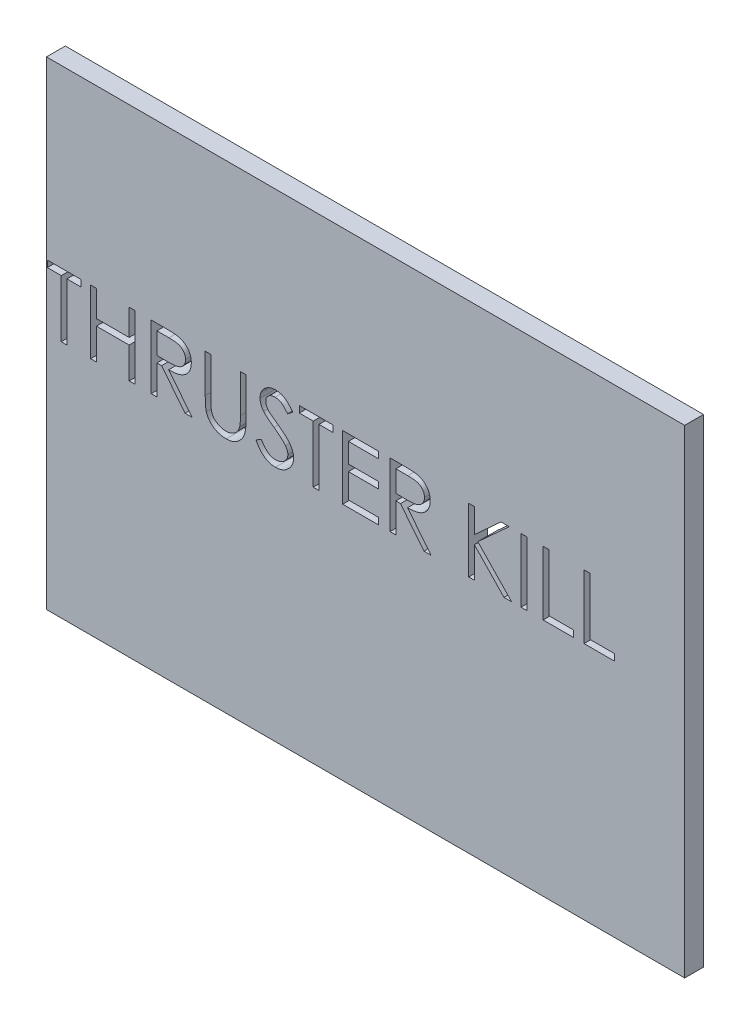
from build123d import *

# Parameters (mm, degrees)
SKETCH1_W               = 101.6
SKETCH1_H               = 76.2
BOSS_EXTRUDE1_DEPTH     = 3
SKETCH2_W               = 0.911794872
SKETCH2_H               = 10.16
CUT_EXTRUDE1_DEPTH      = 1
CUT_EXTRUDE1_DEPTH_BACK = 4


with BuildPart() as part:
    # Sketch1 → Boss-Extrude1 (new body)
    with BuildSketch(Plane.XY):
        Rectangle(SKETCH1_W, SKETCH1_H)
    extrude(amount=BOSS_EXTRUDE1_DEPTH)

    # Sketch2 → Cut-Extrude1 (cut, two sides)
    with BuildSketch(Plane.XY.offset(3)) as cut_extrude1_sk:
        Polygon((-50.66974359, 9.117948718), (-50.66974359, 10.16), (-45.329230769, 10.16), (-45.329230769, 9.117948718), (-47.543589744, 9.117948718), (-47.543589744, 0), (-48.455384615, 0), (-48.455384615, 9.117948718), align=None)
        Polygon((-43.766153846, 10.16), (-42.854358974, 10.16), (-42.854358974, 5.991794872), (-37.644102564, 5.991794872), (-37.644102564, 10.16), (-36.732307692, 10.16), (-36.732307692, 0), (-37.644102564, 0), (-37.644102564, 4.94974359), (-42.854358974, 4.94974359), (-42.854358974, 0), (-43.766153846, 0), align=None)
        with BuildLine():
            Line((-34.127179487, 10.16), (-32.093958333, 10.16))
            add(Edge.make_bspline(
                [(-32.093958333, 10.16), (-31.958275515, 10.159548356), (-31.697749473, 10.15868115), (-31.324519636, 10.153845678), (-30.985387263, 10.139986405), (-30.680529673, 10.128059775), (-30.409952457, 10.106311739), (-30.172825922, 10.085525404), (-29.970242205, 10.058315005), (-29.847608534, 10.033044406), (-29.792083333, 10.021602564)],
                knots=[0, 0, 0, 0, 0.000407056, 0.000781593, 0.001119667, 0.001425287, 0.00169674, 0.001933889, 0.0021394, 0.002309438, 0.002309438, 0.002309438, 0.002309438], degree=3))
            add(Edge.make_bspline(
                [(-29.792083333, 10.021602564), (-29.717750962, 10.003236868), (-29.570671929, 9.966897266), (-29.358908309, 9.890088825), (-29.157118157, 9.801204429), (-28.966139696, 9.696806886), (-28.786929513, 9.57612124), (-28.617639788, 9.441230919), (-28.457502329, 9.292874002), (-28.312993368, 9.127310005), (-28.176736007, 8.953613165), (-28.061815879, 8.765787403), (-27.962751584, 8.569375654), (-27.883879455, 8.362380407), (-27.820370823, 8.146809092), (-27.775590654, 7.920709042), (-27.748735778, 7.685110326), (-27.746001706, 7.524414225), (-27.744615385, 7.442932692)],
                knots=[0, 0, 0, 0, 0.00022956, 0.000454224, 0.000674718, 0.00089059, 0.001106221, 0.001322045, 0.001539474, 0.001760044, 0.001980679, 0.002200948, 0.002419395, 0.002639748, 0.002864522, 0.003092834, 0.003330402, 0.003574768, 0.003574768, 0.003574768, 0.003574768], degree=3))
            add(Edge.make_bspline(
                [(-27.744615385, 7.442932692), (-27.748879676, 7.307557646), (-27.757200414, 7.043405867), (-27.834779572, 6.660051994), (-27.961856555, 6.302451012), (-28.136966445, 5.971053183), (-28.359962409, 5.672318281), (-28.627968088, 5.409927702), (-28.941132995, 5.190355842), (-29.232664952, 5.038092843), (-29.4901896, 4.940577428), (-29.702194874, 4.871964455), (-29.933456729, 4.818952579), (-30.181759391, 4.771461454), (-30.448136174, 4.735606249), (-30.731948631, 4.709345278), (-31.033399174, 4.692932382), (-31.240486301, 4.690488162), (-31.347019231, 4.689230769)],
                knots=[0, 0, 0, 0, 0.000405752, 0.000791727, 0.001167671, 0.001540962, 0.001911786, 0.002281672, 0.002661169, 0.003055321, 0.003264715, 0.003486782, 0.00372324, 0.003975915, 0.004245039, 0.004529174, 0.004830832, 0.005150425, 0.005150425, 0.005150425, 0.005150425], degree=3))
            Line((-31.347019231, 4.689230769), (-27.614358974, 0))
            Line((-27.614358974, 0), (-28.741891026, 0))
            Line((-28.741891026, 0), (-32.474551282, 4.689230769))
            Line((-32.474551282, 4.689230769), (-33.215384615, 4.689230769))
            Line((-33.215384615, 4.689230769), (-33.215384615, 0))
            Line((-33.215384615, 0), (-34.127179487, 0))
            Line((-34.127179487, 0), (-34.127179487, 10.16))
        make_face()
        with BuildLine():
            Line((-33.215384615, 9.117948718), (-33.215384615, 5.731282051))
            Line((-33.215384615, 5.731282051), (-31.355160256, 5.717035256))
            add(Edge.make_bspline(
                [(-31.355160256, 5.717035256), (-31.268306658, 5.716996832), (-31.099959646, 5.716922355), (-30.856408002, 5.728515717), (-30.629636478, 5.741704321), (-30.420512466, 5.761877278), (-30.228942544, 5.787875475), (-30.055022465, 5.820396138), (-29.898468326, 5.858284411), (-29.715882854, 5.916926845), (-29.511996237, 6.009835744), (-29.290416914, 6.145008734), (-29.101724413, 6.31502652), (-28.942305704, 6.509440896), (-28.814204269, 6.723196406), (-28.72389042, 6.953730781), (-28.66658093, 7.195224106), (-28.659821496, 7.361203984), (-28.656410256, 7.444967949)],
                knots=[0, 0, 0, 0, 0.000260521, 0.000504963, 0.000731326, 0.000941943, 0.001135078, 0.001311113, 0.001472528, 0.001617988, 0.001885808, 0.002142751, 0.002393575, 0.002643746, 0.002894711, 0.003137726, 0.003384093, 0.003635098, 0.003635098, 0.003635098, 0.003635098], degree=3))
            add(Edge.make_bspline(
                [(-28.656410256, 7.444967949), (-28.659899842, 7.526673431), (-28.666814928, 7.688583884), (-28.723271925, 7.925619327), (-28.8187451, 8.149333673), (-28.947406225, 8.358816864), (-29.104158058, 8.548970657), (-29.287960623, 8.711667536), (-29.493788275, 8.845923125), (-29.686164096, 8.931715269), (-29.858112553, 8.984314615), (-30.007405509, 9.021329422), (-30.176094827, 9.051067651), (-30.364999587, 9.07489448), (-30.57331335, 9.095373975), (-30.802089411, 9.10916771), (-31.049809893, 9.117335955), (-31.221504985, 9.11773971), (-31.310384615, 9.117948718)],
                knots=[0, 0, 0, 0, 0.000244917, 0.000485336, 0.000726125, 0.00097186, 0.001220462, 0.001462666, 0.001705408, 0.00195504, 0.002091509, 0.002244532, 0.002416195, 0.002605025, 0.002815642, 0.003044035, 0.00329247, 0.003559096, 0.003559096, 0.003559096, 0.003559096], degree=3))
            Line((-31.310384615, 9.117948718), (-33.215384615, 9.117948718))
        make_face(mode=Mode.SUBTRACT)
        with BuildLine():
            Line((-25.53025641, 10.16), (-24.618461538, 10.16))
            Line((-24.618461538, 10.16), (-24.618461538, 4.072548077))
            add(Edge.make_bspline(
                [(-24.618461538, 4.072548077), (-24.61859723, 3.986389141), (-24.618854727, 3.822887713), (-24.617134744, 3.590170589), (-24.612317834, 3.383276822), (-24.609280982, 3.20140891), (-24.602525066, 3.045401392), (-24.597015307, 2.914409062), (-24.589930719, 2.809052177), (-24.581416298, 2.747566974), (-24.57775641, 2.721137821)],
                knots=[0, 0, 0, 0, 0.000258478, 0.000490506, 0.000698142, 0.000879325, 0.001036159, 0.001166558, 0.001272704, 0.001352729, 0.001352729, 0.001352729, 0.001352729], degree=3))
            add(Edge.make_bspline(
                [(-24.57775641, 2.721137821), (-24.562726987, 2.625788359), (-24.533514995, 2.440462037), (-24.459067224, 2.176568281), (-24.355094135, 1.938732962), (-24.231888045, 1.719534472), (-24.069523665, 1.525073929), (-23.875021974, 1.345933817), (-23.639374509, 1.189261379), (-23.377360865, 1.046003022), (-23.094955718, 0.930860954), (-22.806379014, 0.843794502), (-22.515968537, 0.790733468), (-22.321546298, 0.784589457), (-22.225, 0.781538462)],
                knots=[0, 0, 0, 0, 0.000289443, 0.000562577, 0.000819665, 0.001066812, 0.001314119, 0.001576296, 0.001857427, 0.002160687, 0.002470989, 0.00277042, 0.003063872, 0.003353336, 0.003353336, 0.003353336, 0.003353336], degree=3))
            add(Edge.make_bspline(
                [(-22.225, 0.781538462), (-22.142112571, 0.784655695), (-21.976816448, 0.790872159), (-21.731216067, 0.829368199), (-21.492020323, 0.898748127), (-21.258048063, 0.98827154), (-21.038734348, 1.106555976), (-20.833956814, 1.243195898), (-20.651181508, 1.403465184), (-20.484389148, 1.580830756), (-20.339144877, 1.780953146), (-20.213244649, 1.999474827), (-20.110117951, 2.23968436), (-20.059191604, 2.40849834), (-20.033028846, 2.495224359)],
                knots=[0, 0, 0, 0, 0.00024871, 0.000495983, 0.000743398, 0.000994734, 0.001246028, 0.001489325, 0.001731717, 0.001973647, 0.002218301, 0.002471754, 0.002728842, 0.003000455, 0.003000455, 0.003000455, 0.003000455], degree=3))
            add(Edge.make_bspline(
                [(-20.033028846, 2.495224359), (-20.024319911, 2.531070506), (-20.004912894, 2.610950168), (-19.986778615, 2.745994829), (-19.967891101, 2.905330811), (-19.954785949, 3.09010293), (-19.942009835, 3.29969204), (-19.934366401, 3.535189976), (-19.930833528, 3.79574161), (-19.929780719, 3.977568343), (-19.929230769, 4.072548077)],
                knots=[0, 0, 0, 0, 0.000110599, 0.000246459, 0.000408284, 0.000592011, 0.000801997, 0.001038227, 0.001298772, 0.001583715, 0.001583715, 0.001583715, 0.001583715], degree=3))
            Line((-19.929230769, 4.072548077), (-19.929230769, 10.16))
            Line((-19.929230769, 10.16), (-19.017435897, 10.16))
            Line((-19.017435897, 10.16), (-19.017435897, 4.023701923))
            add(Edge.make_bspline(
                [(-19.017435897, 4.023701923), (-19.018173573, 3.913107772), (-19.019613191, 3.697276561), (-19.03209715, 3.38100633), (-19.052002041, 3.08098739), (-19.080125176, 2.797179412), (-19.117389162, 2.530597967), (-19.158828088, 2.278906411), (-19.211600676, 2.043911438), (-19.273238206, 1.823780763), (-19.343700848, 1.61423653), (-19.43497001, 1.415365808), (-19.537802273, 1.221122865), (-19.659764808, 1.034445612), (-19.796812708, 0.854507503), (-19.951975301, 0.682399789), (-20.120120865, 0.515372157), (-20.304044615, 0.357709085), (-20.500714711, 0.213121612), (-20.709546131, 0.085982939), (-20.928934697, -0.021491334), (-21.158310126, -0.109958588), (-21.397770304, -0.176476396), (-21.647321268, -0.226043134), (-21.907531041, -0.254207518), (-22.084502728, -0.258393235), (-22.17411859, -0.260512821)],
                knots=[0, 0, 0, 0, 0.000331772, 0.000647473, 0.000949378, 0.001233709, 0.001502833, 0.001756792, 0.001998739, 0.002224909, 0.002442463, 0.002661099, 0.002880549, 0.003101278, 0.003329236, 0.003558426, 0.003795889, 0.004039823, 0.004284477, 0.004527415, 0.004772264, 0.005016436, 0.005263851, 0.005516911, 0.005778978, 0.006047824, 0.006047824, 0.006047824, 0.006047824], degree=3))
            add(Edge.make_bspline(
                [(-22.17411859, -0.260512821), (-22.271855185, -0.258234759), (-22.463614035, -0.253765211), (-22.746172538, -0.228154027), (-23.01705032, -0.179913203), (-23.279108294, -0.118488909), (-23.528778674, -0.033772689), (-23.769406501, 0.065209297), (-23.996870559, 0.186773001), (-24.214860989, 0.322026964), (-24.417552281, 0.4742082), (-24.603617886, 0.640077962), (-24.773364984, 0.816979172), (-24.9239324, 1.006827091), (-25.057814739, 1.208145189), (-25.173145873, 1.421502982), (-25.272171747, 1.646817865), (-25.323281096, 1.803436299), (-25.34911859, 1.882612179)],
                knots=[0, 0, 0, 0, 0.000293254, 0.000575362, 0.000850069, 0.001118113, 0.001381991, 0.001640156, 0.001897799, 0.002154742, 0.002409149, 0.002657099, 0.002901821, 0.003143709, 0.003383048, 0.003626208, 0.003870473, 0.004120205, 0.004120205, 0.004120205, 0.004120205], degree=3))
            add(Edge.make_bspline(
                [(-25.34911859, 1.882612179), (-25.36414714, 1.936699881), (-25.396744401, 2.054017311), (-25.431652122, 2.248179232), (-25.460997342, 2.471742536), (-25.48859062, 2.724722525), (-25.504872624, 3.007315281), (-25.519147246, 3.319398305), (-25.530356973, 3.66134896), (-25.530290868, 3.899541497), (-25.53025641, 4.023701923)],
                knots=[0, 0, 0, 0, 0.000168337, 0.000365126, 0.000591076, 0.000844831, 0.001128324, 0.001440044, 0.001782119, 0.002154576, 0.002154576, 0.002154576, 0.002154576], degree=3))
            Line((-25.53025641, 4.023701923), (-25.53025641, 10.16))
        make_face()
        with BuildLine():
            Line((-17.454358974, 1.959951923), (-16.595480769, 2.474871795))
            add(Edge.make_bspline(
                [(-16.595480769, 2.474871795), (-16.515599258, 2.341153466), (-16.362549364, 2.084954308), (-16.107239133, 1.738765254), (-15.842693311, 1.444525393), (-15.566952846, 1.203946441), (-15.281700836, 1.014538244), (-14.985075126, 0.880419765), (-14.67807531, 0.796771105), (-14.469145588, 0.786610854), (-14.364839744, 0.781538462)],
                knots=[0, 0, 0, 0, 0.000467073, 0.000894893, 0.001288224, 0.001651812, 0.001989947, 0.002311498, 0.002624967, 0.002937483, 0.002937483, 0.002937483, 0.002937483], degree=3))
            add(Edge.make_bspline(
                [(-14.364839744, 0.781538462), (-14.275760171, 0.784019454), (-14.09915971, 0.788938027), (-13.839173313, 0.836198869), (-13.586677567, 0.908805506), (-13.346876493, 1.012788553), (-13.123078938, 1.138593986), (-12.92682636, 1.290547461), (-12.757165642, 1.460672904), (-12.618382613, 1.65046941), (-12.51190571, 1.854590047), (-12.430068163, 2.064106523), (-12.384652749, 2.282310138), (-12.377811431, 2.429225082), (-12.374358974, 2.503365385)],
                knots=[0, 0, 0, 0, 0.000266999, 0.000529326, 0.000790165, 0.001053666, 0.001311662, 0.001558356, 0.001795819, 0.002030298, 0.002260642, 0.002484798, 0.00270314, 0.00292558, 0.00292558, 0.00292558, 0.00292558], degree=3))
            add(Edge.make_bspline(
                [(-12.374358974, 2.503365385), (-12.378638688, 2.587957108), (-12.38733872, 2.759919721), (-12.460872387, 3.013628428), (-12.576549058, 3.264704003), (-12.683265761, 3.420010534), (-12.738669872, 3.500641026)],
                knots=[0, 0, 0, 0, 0.000253363, 0.00051505, 0.000786411, 0.00107941, 0.00107941, 0.00107941, 0.00107941], degree=3))
            add(Edge.make_bspline(
                [(-12.738669872, 3.500641026), (-12.784159426, 3.558834091), (-12.879659055, 3.681003152), (-13.043837435, 3.862853321), (-13.236488784, 4.05043136), (-13.451020246, 4.250899937), (-13.695246584, 4.454935369), (-13.961518454, 4.672267285), (-14.256634113, 4.89463072), (-14.463606366, 5.043757939), (-14.570400641, 5.120705128)],
                knots=[0, 0, 0, 0, 0.000221544, 0.000465104, 0.000734228, 0.001028039, 0.001345708, 0.001688678, 0.0020591, 0.002453987, 0.002453987, 0.002453987, 0.002453987], degree=3))
            add(Edge.make_bspline(
                [(-14.570400641, 5.120705128), (-14.677295441, 5.196842971), (-14.88167016, 5.342412729), (-15.167481359, 5.558455793), (-15.423061857, 5.755977426), (-15.647275688, 5.936837073), (-15.840024232, 6.101059262), (-16.002826362, 6.247066994), (-16.131534859, 6.378808988), (-16.203106488, 6.464272997), (-16.235240385, 6.502644231)],
                knots=[0, 0, 0, 0, 0.000393695, 0.000752714, 0.001074735, 0.001362715, 0.001616804, 0.001834348, 0.002018581, 0.002168694, 0.002168694, 0.002168694, 0.002168694], degree=3))
            add(Edge.make_bspline(
                [(-16.235240385, 6.502644231), (-16.280154973, 6.562446098), (-16.368485539, 6.680054495), (-16.485081715, 6.863877511), (-16.584182828, 7.05205019), (-16.661870055, 7.245078185), (-16.727289478, 7.440251579), (-16.771290786, 7.640116909), (-16.798842955, 7.843777356), (-16.801664493, 7.980831403), (-16.803076923, 8.049439103)],
                knots=[0, 0, 0, 0, 0.000224303, 0.000441123, 0.000652319, 0.000861327, 0.00106471, 0.001269129, 0.001474368, 0.00168009, 0.00168009, 0.00168009, 0.00168009], degree=3))
            add(Edge.make_bspline(
                [(-16.803076923, 8.049439103), (-16.799288088, 8.156931248), (-16.791791401, 8.36961797), (-16.728391499, 8.680313181), (-16.628321614, 8.976945752), (-16.488128454, 9.256578949), (-16.307404252, 9.511931625), (-16.098265081, 9.745941062), (-15.849166595, 9.942663575), (-15.57585498, 10.114547721), (-15.276697054, 10.249083321), (-14.963214889, 10.350570052), (-14.634910246, 10.408073498), (-14.412542289, 10.416325638), (-14.299711538, 10.420512821)],
                knots=[0, 0, 0, 0, 0.000322214, 0.000637541, 0.000947121, 0.001259319, 0.001572113, 0.001883301, 0.002197344, 0.00252095, 0.002849743, 0.003178656, 0.003507241, 0.003845706, 0.003845706, 0.003845706, 0.003845706], degree=3))
            add(Edge.make_bspline(
                [(-14.299711538, 10.420512821), (-14.179985807, 10.416383356), (-13.941889541, 10.40817117), (-13.591662103, 10.336768051), (-13.254464138, 10.218619815), (-12.983211689, 10.084540739), (-12.77091773, 9.95062783), (-12.609017455, 9.828650283), (-12.444955369, 9.688224253), (-12.277408101, 9.528975699), (-12.109214644, 9.349443416), (-11.937877994, 9.150856959), (-11.762997488, 8.934429928), (-11.650494763, 8.779926806), (-11.592820513, 8.700721154)],
                knots=[0, 0, 0, 0, 0.000358904, 0.000713746, 0.001067113, 0.001428462, 0.001618744, 0.001819421, 0.002035982, 0.002266317, 0.002512516, 0.002773672, 0.003053066, 0.003346962, 0.003346962, 0.003346962, 0.003346962], degree=3))
            Line((-11.592820513, 8.700721154), (-12.417099359, 8.075897436))
            add(Edge.make_bspline(
                [(-12.417099359, 8.075897436), (-12.466871552, 8.140017749), (-12.562721157, 8.263498479), (-12.708239896, 8.436425498), (-12.845395971, 8.594388764), (-12.980525132, 8.731592679), (-13.106490645, 8.855550872), (-13.228750402, 8.961678623), (-13.345544976, 9.05101578), (-13.492768922, 9.146355943), (-13.677732356, 9.240862822), (-13.909916038, 9.32083386), (-14.152555054, 9.368890839), (-14.317813641, 9.375244867), (-14.401474359, 9.378461538)],
                knots=[0, 0, 0, 0, 0.000243483, 0.000468892, 0.000677969, 0.000870836, 0.001046435, 0.00120803, 0.001356199, 0.001487169, 0.001733838, 0.001977134, 0.002221814, 0.00247268, 0.00247268, 0.00247268, 0.00247268], degree=3))
            add(Edge.make_bspline(
                [(-14.401474359, 9.378461538), (-14.506431578, 9.374944147), (-14.708831689, 9.368161188), (-14.996186202, 9.294080316), (-15.254813139, 9.177438116), (-15.477034299, 9.01396378), (-15.662053639, 8.820282269), (-15.795891199, 8.597404221), (-15.876445962, 8.351293018), (-15.886275848, 8.179613239), (-15.891282051, 8.092179487)],
                knots=[0, 0, 0, 0, 0.000314228, 0.000605959, 0.000883718, 0.001160542, 0.001428362, 0.001682117, 0.001934423, 0.002196276, 0.002196276, 0.002196276, 0.002196276], degree=3))
            add(Edge.make_bspline(
                [(-15.891282051, 8.092179487), (-15.890140861, 8.037746624), (-15.887856614, 7.928791888), (-15.855998344, 7.767824332), (-15.815070006, 7.607263415), (-15.750212538, 7.447831004), (-15.660673028, 7.286738807), (-15.543092289, 7.121212849), (-15.395007932, 6.949794175), (-15.281572947, 6.838303055), (-15.221682692, 6.779439103)],
                knots=[0, 0, 0, 0, 0.000163024, 0.000326314, 0.000490717, 0.000659656, 0.000840931, 0.001042514, 0.001267683, 0.001519538, 0.001519538, 0.001519538, 0.001519538], degree=3))
            add(Edge.make_bspline(
                [(-15.221682692, 6.779439103), (-15.199442823, 6.759592193), (-15.146605983, 6.71244048), (-15.050010725, 6.635246888), (-14.922451059, 6.540025126), (-14.767257926, 6.422205945), (-14.581569813, 6.285535186), (-14.365366302, 6.131760358), (-14.121057395, 5.955889425), (-13.947693205, 5.832931536), (-13.856025641, 5.767916667)],
                knots=[0, 0, 0, 0, 8.9412e-05, 0.000212423, 0.000370768, 0.000566968, 0.000796961, 0.001062419, 0.001362894, 0.00170004, 0.00170004, 0.00170004, 0.00170004], degree=3))
            add(Edge.make_bspline(
                [(-13.856025641, 5.767916667), (-13.745757961, 5.687677749), (-13.532239882, 5.532306205), (-13.228433879, 5.298870974), (-12.95297071, 5.070567737), (-12.704883239, 4.848854455), (-12.481720556, 4.635412905), (-12.285958487, 4.427675215), (-12.115602341, 4.227129667), (-11.932202095, 3.970016133), (-11.744799968, 3.654240186), (-11.583861192, 3.267352499), (-11.482382103, 2.878960894), (-11.469111647, 2.617916135), (-11.462564103, 2.48911859)],
                knots=[0, 0, 0, 0, 0.000409107, 0.000792179, 0.001149185, 0.001482153, 0.001790184, 0.002075265, 0.002338199, 0.002578816, 0.003022128, 0.003436382, 0.003832761, 0.0042188, 0.0042188, 0.0042188, 0.0042188], degree=3))
            add(Edge.make_bspline(
                [(-11.462564103, 2.48911859), (-11.464471681, 2.398031678), (-11.468249793, 2.217626702), (-11.511679188, 1.952726251), (-11.575308845, 1.695443497), (-11.671211216, 1.448958668), (-11.788263584, 1.208762443), (-11.936791892, 0.981155509), (-12.108953628, 0.761100363), (-12.306445928, 0.554464857), (-12.522551748, 0.364774185), (-12.750959273, 0.196033824), (-12.992042351, 0.055337205), (-13.244493144, -0.059473239), (-13.508369642, -0.149268821), (-13.783583094, -0.214330179), (-14.070587161, -0.254261042), (-14.265660559, -0.25840563), (-14.364839744, -0.260512821)],
                knots=[0, 0, 0, 0, 0.000272998, 0.000540694, 0.000803305, 0.001066767, 0.001332545, 0.001603532, 0.001880394, 0.002169752, 0.002459624, 0.002742136, 0.003020342, 0.003295403, 0.003572803, 0.003855176, 0.004142724, 0.004440122, 0.004440122, 0.004440122, 0.004440122], degree=3))
            add(Edge.make_bspline(
                [(-14.364839744, -0.260512821), (-14.441577768, -0.259028933), (-14.59408738, -0.256079847), (-14.819666904, -0.230008473), (-15.040689255, -0.193121567), (-15.254380999, -0.134559124), (-15.463495314, -0.063505956), (-15.667122715, 0.023981318), (-15.865361888, 0.128824394), (-16.059323786, 0.248697952), (-16.248515104, 0.388202719), (-16.431161331, 0.550685783), (-16.613255195, 0.731665877), (-16.789422037, 0.936057684), (-16.963225222, 1.16055909), (-17.131237976, 1.407270548), (-17.296938048, 1.674848238), (-17.400905235, 1.863142315), (-17.454358974, 1.959951923)],
                knots=[0, 0, 0, 0, 0.000230128, 0.000457358, 0.000680541, 0.000901711, 0.001121188, 0.001342732, 0.001565777, 0.00179338, 0.002026219, 0.002269949, 0.002526116, 0.002795886, 0.003078816, 0.003377451, 0.00369092, 0.004022636, 0.004022636, 0.004022636, 0.004022636], degree=3))
        make_face()
        Polygon((-10.550769231, 9.117948718), (-10.550769231, 10.16), (-5.21025641, 10.16), (-5.21025641, 9.117948718), (-7.424615385, 9.117948718), (-7.424615385, 0), (-8.336410256, 0), (-8.336410256, 9.117948718), align=None)
        Polygon((-3.647179487, 10.16), (2.084102564, 10.16), (2.084102564, 9.117948718), (-2.735384615, 9.117948718), (-2.735384615, 5.991794872), (2.084102564, 5.991794872), (2.084102564, 4.94974359), (-2.735384615, 4.94974359), (-2.735384615, 1.042051282), (2.084102564, 1.042051282), (2.084102564, 0), (-3.647179487, 0), align=None)
        with BuildLine():
            Line((3.907692308, 10.16), (5.940913462, 10.16))
            add(Edge.make_bspline(
                [(5.940913462, 10.16), (6.07659628, 10.159548356), (6.337122322, 10.15868115), (6.710352159, 10.153845678), (7.049484532, 10.139986405), (7.354342122, 10.128059775), (7.624919338, 10.106311739), (7.862045873, 10.085525404), (8.06462959, 10.058315005), (8.187263261, 10.033044406), (8.242788462, 10.021602564)],
                knots=[0, 0, 0, 0, 0.000407056, 0.000781593, 0.001119667, 0.001425287, 0.00169674, 0.001933889, 0.0021394, 0.002309438, 0.002309438, 0.002309438, 0.002309438], degree=3))
            add(Edge.make_bspline(
                [(8.242788462, 10.021602564), (8.317120833, 10.003236868), (8.464199866, 9.966897266), (8.675963486, 9.890088825), (8.877753638, 9.801204429), (9.068732099, 9.696806886), (9.247942282, 9.57612124), (9.417232007, 9.441230919), (9.577369466, 9.292874002), (9.721878427, 9.127310005), (9.858135788, 8.953613165), (9.973055916, 8.765787403), (10.072120211, 8.569375654), (10.15099234, 8.362380407), (10.214500972, 8.146809092), (10.259281141, 7.920709042), (10.286136017, 7.685110326), (10.288870089, 7.524414225), (10.29025641, 7.442932692)],
                knots=[0, 0, 0, 0, 0.00022956, 0.000454224, 0.000674718, 0.00089059, 0.001106221, 0.001322045, 0.001539474, 0.001760044, 0.001980679, 0.002200948, 0.002419395, 0.002639748, 0.002864522, 0.003092834, 0.003330402, 0.003574768, 0.003574768, 0.003574768, 0.003574768], degree=3))
            add(Edge.make_bspline(
                [(10.29025641, 7.442932692), (10.285992119, 7.307557646), (10.277671381, 7.043405867), (10.200092223, 6.660051994), (10.07301524, 6.302451012), (9.89790535, 5.971053183), (9.674909386, 5.672318281), (9.406903707, 5.409927702), (9.0937388, 5.190355842), (8.802206843, 5.038092843), (8.544682195, 4.940577428), (8.332676921, 4.871964455), (8.101415066, 4.818952579), (7.853112404, 4.771461454), (7.586735621, 4.735606249), (7.302923164, 4.709345278), (7.001472621, 4.692932382), (6.794385493, 4.690488162), (6.687852564, 4.689230769)],
                knots=[0, 0, 0, 0, 0.000405752, 0.000791727, 0.001167671, 0.001540962, 0.001911786, 0.002281672, 0.002661169, 0.003055321, 0.003264715, 0.003486782, 0.00372324, 0.003975915, 0.004245039, 0.004529174, 0.004830832, 0.005150425, 0.005150425, 0.005150425, 0.005150425], degree=3))
            Line((6.687852564, 4.689230769), (10.420512821, 0))
            Line((10.420512821, 0), (9.292980769, 0))
            Line((9.292980769, 0), (5.560320513, 4.689230769))
            Line((5.560320513, 4.689230769), (4.819487179, 4.689230769))
            Line((4.819487179, 4.689230769), (4.819487179, 0))
            Line((4.819487179, 0), (3.907692308, 0))
            Line((3.907692308, 0), (3.907692308, 10.16))
        make_face()
        with BuildLine():
            Line((4.819487179, 9.117948718), (4.819487179, 5.731282051))
            Line((4.819487179, 5.731282051), (6.679711538, 5.717035256))
            add(Edge.make_bspline(
                [(6.679711538, 5.717035256), (6.766565137, 5.716996832), (6.934912149, 5.716922355), (7.178463793, 5.728515717), (7.405235317, 5.741704321), (7.614359329, 5.761877278), (7.805929251, 5.787875475), (7.97984933, 5.820396138), (8.136403469, 5.858284411), (8.318988941, 5.916926845), (8.522875558, 6.009835744), (8.744454881, 6.145008734), (8.933147382, 6.31502652), (9.09256609, 6.509440896), (9.220667526, 6.723196406), (9.310981375, 6.953730781), (9.368290865, 7.195224106), (9.375050299, 7.361203984), (9.378461538, 7.444967949)],
                knots=[0, 0, 0, 0, 0.000260521, 0.000504963, 0.000731326, 0.000941943, 0.001135078, 0.001311113, 0.001472528, 0.001617988, 0.001885808, 0.002142751, 0.002393575, 0.002643746, 0.002894711, 0.003137726, 0.003384093, 0.003635098, 0.003635098, 0.003635098, 0.003635098], degree=3))
            add(Edge.make_bspline(
                [(9.378461538, 7.444967949), (9.374971953, 7.526673431), (9.368056867, 7.688583884), (9.31159987, 7.925619327), (9.216126695, 8.149333673), (9.08746557, 8.358816864), (8.930713737, 8.548970657), (8.746911172, 8.711667536), (8.54108352, 8.845923125), (8.348707699, 8.931715269), (8.176759242, 8.984314615), (8.027466286, 9.021329422), (7.858776968, 9.051067651), (7.669872208, 9.07489448), (7.461558445, 9.095373975), (7.232782384, 9.10916771), (6.985061902, 9.117335955), (6.81336681, 9.11773971), (6.724487179, 9.117948718)],
                knots=[0, 0, 0, 0, 0.000244917, 0.000485336, 0.000726125, 0.00097186, 0.001220462, 0.001462666, 0.001705408, 0.00195504, 0.002091509, 0.002244532, 0.002416195, 0.002605025, 0.002815642, 0.003044035, 0.00329247, 0.003559096, 0.003559096, 0.003559096, 0.003559096], degree=3))
            Line((6.724487179, 9.117948718), (4.819487179, 9.117948718))
        make_face(mode=Mode.SUBTRACT)
        Polygon((16.412307692, 10.16), (17.324102564, 10.16), (17.324102564, 6.290977564), (21.559471154, 10.16), (22.86, 10.16), (17.867516026, 5.601025641), (23.250769231, 0), (22.035721154, 0), (17.324102564, 4.902932692), (17.324102564, 0), (16.412307692, 0), align=None)
        with Locations((25.204615385, 5.08)):
            Rectangle(SKETCH2_W, SKETCH2_H)
        Polygon((28.265641026, 10.16), (29.177435897, 10.16), (29.177435897, 1.042051282), (33.085128205, 1.042051282), (33.085128205, 0), (28.265641026, 0), align=None)
        Polygon((34.778461538, 10.16), (35.69025641, 10.16), (35.69025641, 1.042051282), (39.597948718, 1.042051282), (39.597948718, 0), (34.778461538, 0), align=None)
    extrude(amount=CUT_EXTRUDE1_DEPTH, mode=Mode.SUBTRACT)
    extrude(cut_extrude1_sk.sketch, amount=-CUT_EXTRUDE1_DEPTH_BACK, mode=Mode.SUBTRACT)


solid = part.part
